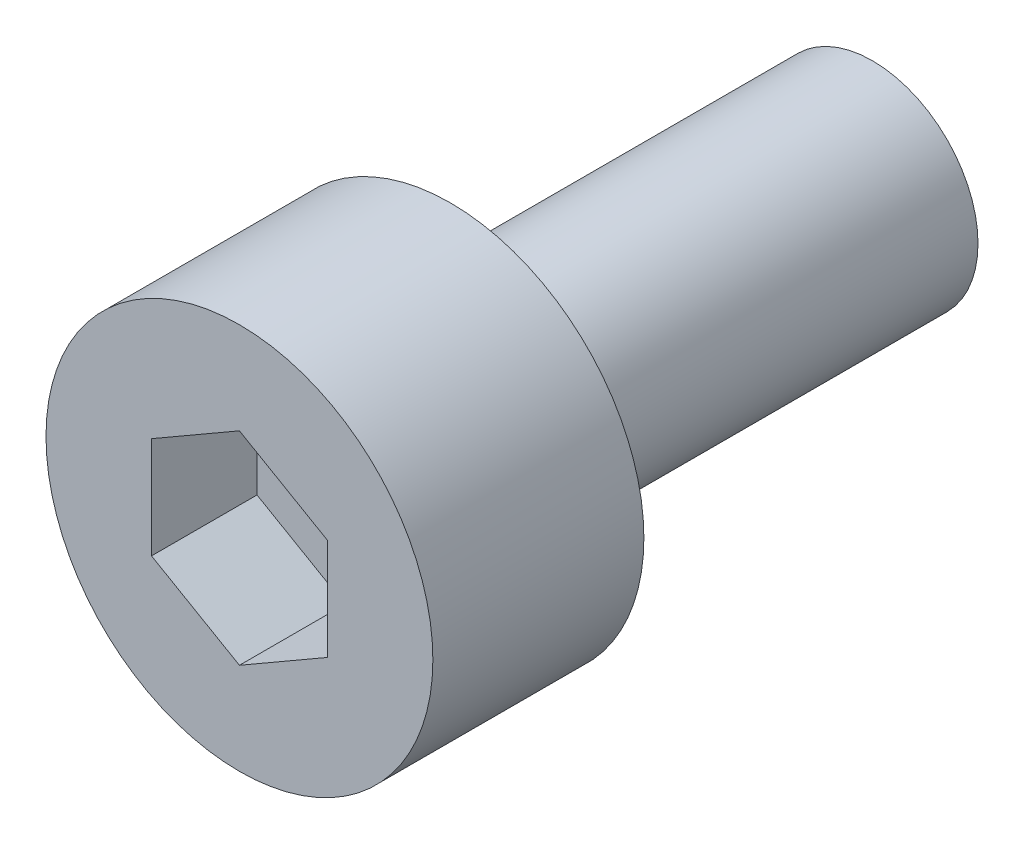
from build123d import *

# Parameters (mm, degrees)
SKETCH_1_R          = 2.75
EXTRUDE_1_DEPTH     = 3
CUT_EXTRUDE_1_DEPTH = 1.5
SKETCH_3_R          = 1.5
EXTRUDE_2_DEPTH     = 6


with BuildPart() as part:
    # 草图1 → 凸台-拉伸1 (new body)
    with BuildSketch(Plane.XY):
        Circle(SKETCH_1_R)
    extrude(amount=EXTRUDE_1_DEPTH)

    # 草图2 → 切除-拉伸1 (cut)
    with BuildSketch(Plane.XY.offset(3)):
        Polygon((0, -1.443375673), (1.25, -0.721687836), (1.25, 0.721687836), (0, 1.443375673), (-1.25, 0.721687836), (-1.25, -0.721687836), align=None)
    extrude(amount=-CUT_EXTRUDE_1_DEPTH, mode=Mode.SUBTRACT)

    # 草图3 → 凸台-拉伸2 (add)
    with BuildSketch(Plane(origin=(0, 0, 0), x_dir=(-1, 0, 0), z_dir=(0, 0, -1))):
        Circle(SKETCH_3_R)
    extrude(amount=EXTRUDE_2_DEPTH)


solid = part.part
